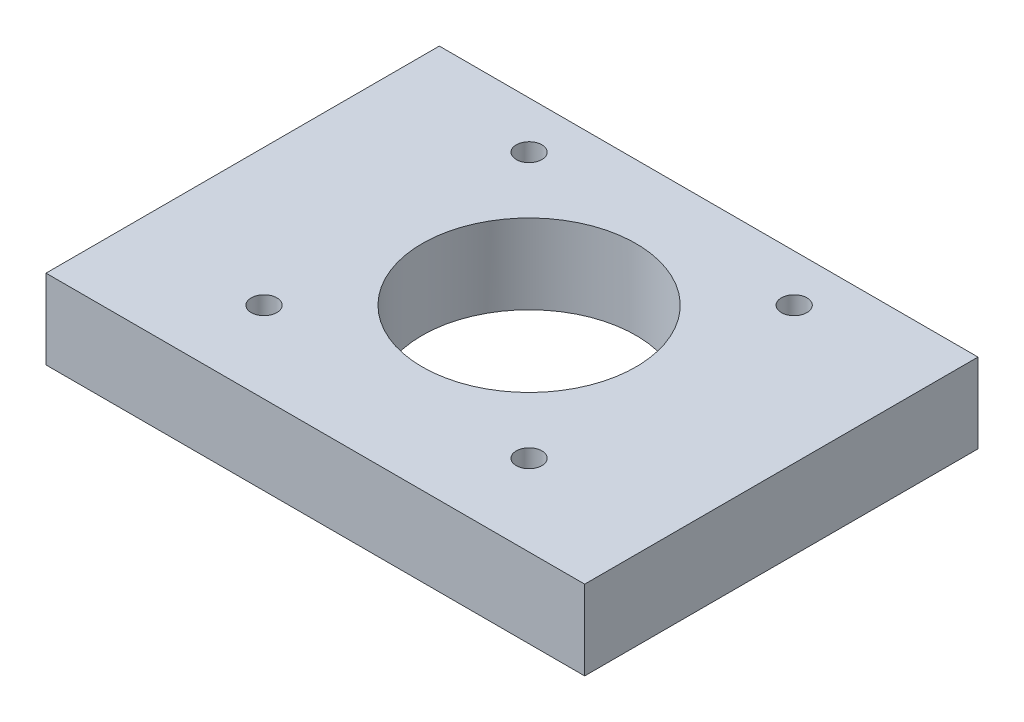
from build123d import *

# Parameters (mm, degrees)
BOSS_EXTRUDE1_DEPTH = 46
CUT_EXTRUDE1_REACH  = 11.3
SKETCH2_R           = 12.5
SKETCH2_R_2         = 1.5


with BuildPart() as part:
    # Sketch1 → Boss-Extrude1 (new body)
    with BuildSketch(Plane.XY):
        Polygon((0, 0), (-31.5, 0), (-31.5, 9.3), (31.5, 9.3), (31.5, 0), align=None)
    extrude(amount=BOSS_EXTRUDE1_DEPTH)

    # Sketch2 → Cut-Extrude1 (cut, up to next)
    with BuildSketch(Plane(origin=(0, 9.3, 0), x_dir=(1, 0, 0), z_dir=(0, 1, 0)), mode=Mode.PRIVATE) as cut_extrude1_sk1:
        with Locations((0, -21)):
            Circle(SKETCH2_R)
    cut_extrude1_tool1 = extrude(cut_extrude1_sk1.sketch, amount=-CUT_EXTRUDE1_REACH, mode=Mode.PRIVATE) & part.part
    add(cut_extrude1_tool1.solids().sort_by_distance((0, 9.3, 21))[0], mode=Mode.SUBTRACT)
    # Sketch2 → Cut-Extrude1 (cut, up to next)
    with BuildSketch(Plane(origin=(0, 9.3, 0), x_dir=(1, 0, 0), z_dir=(0, 1, 0)), mode=Mode.PRIVATE) as cut_extrude1_sk2:
        with Locations((-15.5, -5.5)):
            Circle(SKETCH2_R_2)
    cut_extrude1_tool2 = extrude(cut_extrude1_sk2.sketch, amount=-CUT_EXTRUDE1_REACH, mode=Mode.PRIVATE) & part.part
    add(cut_extrude1_tool2.solids().sort_by_distance((-15.5, 9.3, 5.5))[0], mode=Mode.SUBTRACT)
    # Sketch2 → Cut-Extrude1 (cut, up to next)
    with BuildSketch(Plane(origin=(0, 9.3, 0), x_dir=(1, 0, 0), z_dir=(0, 1, 0)), mode=Mode.PRIVATE) as cut_extrude1_sk3:
        with Locations((-15.5, -36.5)):
            Circle(SKETCH2_R_2)
    cut_extrude1_tool3 = extrude(cut_extrude1_sk3.sketch, amount=-CUT_EXTRUDE1_REACH, mode=Mode.PRIVATE) & part.part
    add(cut_extrude1_tool3.solids().sort_by_distance((-15.5, 9.3, 36.5))[0], mode=Mode.SUBTRACT)
    # Sketch2 → Cut-Extrude1 (cut, up to next)
    with BuildSketch(Plane(origin=(0, 9.3, 0), x_dir=(1, 0, 0), z_dir=(0, 1, 0)), mode=Mode.PRIVATE) as cut_extrude1_sk4:
        with Locations((15.5, -5.5)):
            Circle(SKETCH2_R_2)
    cut_extrude1_tool4 = extrude(cut_extrude1_sk4.sketch, amount=-CUT_EXTRUDE1_REACH, mode=Mode.PRIVATE) & part.part
    add(cut_extrude1_tool4.solids().sort_by_distance((15.5, 9.3, 5.5))[0], mode=Mode.SUBTRACT)
    # Sketch2 → Cut-Extrude1 (cut, up to next)
    with BuildSketch(Plane(origin=(0, 9.3, 0), x_dir=(1, 0, 0), z_dir=(0, 1, 0)), mode=Mode.PRIVATE) as cut_extrude1_sk5:
        with Locations((15.5, -36.5)):
            Circle(SKETCH2_R_2)
    cut_extrude1_tool5 = extrude(cut_extrude1_sk5.sketch, amount=-CUT_EXTRUDE1_REACH, mode=Mode.PRIVATE) & part.part
    add(cut_extrude1_tool5.solids().sort_by_distance((15.5, 9.3, 36.5))[0], mode=Mode.SUBTRACT)


solid = part.part
